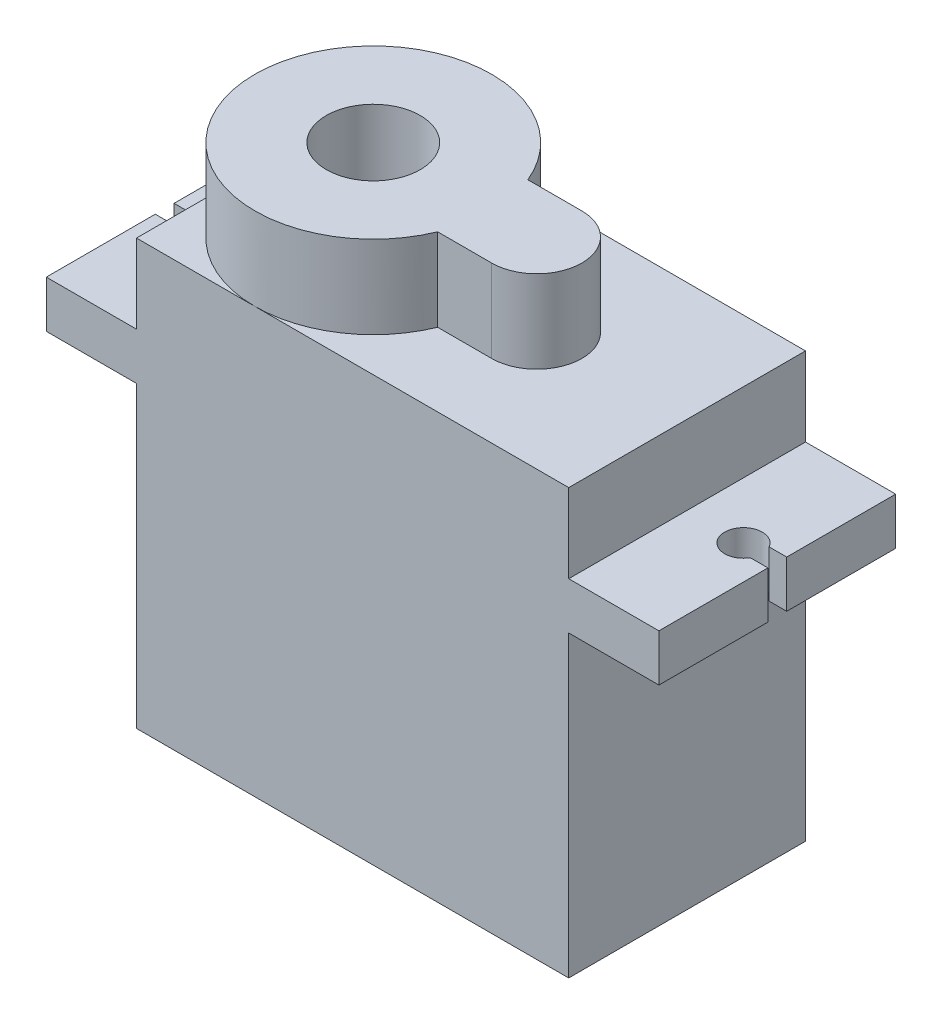
from build123d import *

# Parameters (mm, degrees)
SALIENTE_EXTRUIR1_DEPTH = 12.6
CROQUIS2_R              = 1
CROQUIS2_W              = 0.933974596
CROQUIS2_H              = 1
CORTAR_EXTRUIR2_DEPTH   = 2.5
CROQUIS4_R              = 6.3
CROQUIS4_R_2            = 2.5
CROQUIS4_R_3            = 2.4
CROQUIS4_W              = 4.8
CROQUIS4_H              = 4.8
SALIENTE_EXTRUIR4_DEPTH = 4.4


with BuildPart() as part:
    # Croquis1 → Saliente-Extruir1 (new body)
    with BuildSketch(Plane.XY):
        Polygon((11.5, 0), (-11.5, 0), (-11.5, 15.9), (-16.3, 15.9), (-16.3, 18.4), (-11.5, 18.4), (-11.5, 22.6), (11.5, 22.6), (11.5, 18.4), (16.3, 18.4), (16.3, 15.9), (11.5, 15.9), align=None)
    extrude(amount=SALIENTE_EXTRUIR1_DEPTH)

    # Croquis2 → Cortar-Extruir2 (cut)
    with BuildSketch(Plane(origin=(0, 18.4, 0), x_dir=(1, 0, 0), z_dir=(0, 1, 0))):
        with Locations((-14.5, -6.3)):
            Circle(CROQUIS2_R)
        with Locations((14.5, -6.3)):
            Circle(CROQUIS2_R)
        with Locations((-15.833012702, -6.3)):
            Rectangle(CROQUIS2_W, CROQUIS2_H)
        with Locations((15.833012702, -6.3)):
            Rectangle(CROQUIS2_W, CROQUIS2_H)
    extrude(amount=-CORTAR_EXTRUIR2_DEPTH, mode=Mode.SUBTRACT)

    # Croquis4 → Saliente-Extruir4 (add)
    with BuildSketch(Plane(origin=(0, 22.6, 0), x_dir=(1, 0, 0), z_dir=(0, 1, 0))):
        with Locations((-5.2, -6.3)):
            Circle(CROQUIS4_R)
        with Locations((-5.2, -6.3)):
            Circle(CROQUIS4_R_2, mode=Mode.SUBTRACT)
        with Locations((3.5, -6.3)):
            Circle(CROQUIS4_R_3)
        with Locations((1.1, -6.3)):
            Rectangle(CROQUIS4_W, CROQUIS4_H)
    extrude(amount=SALIENTE_EXTRUIR4_DEPTH)


solid = part.part
